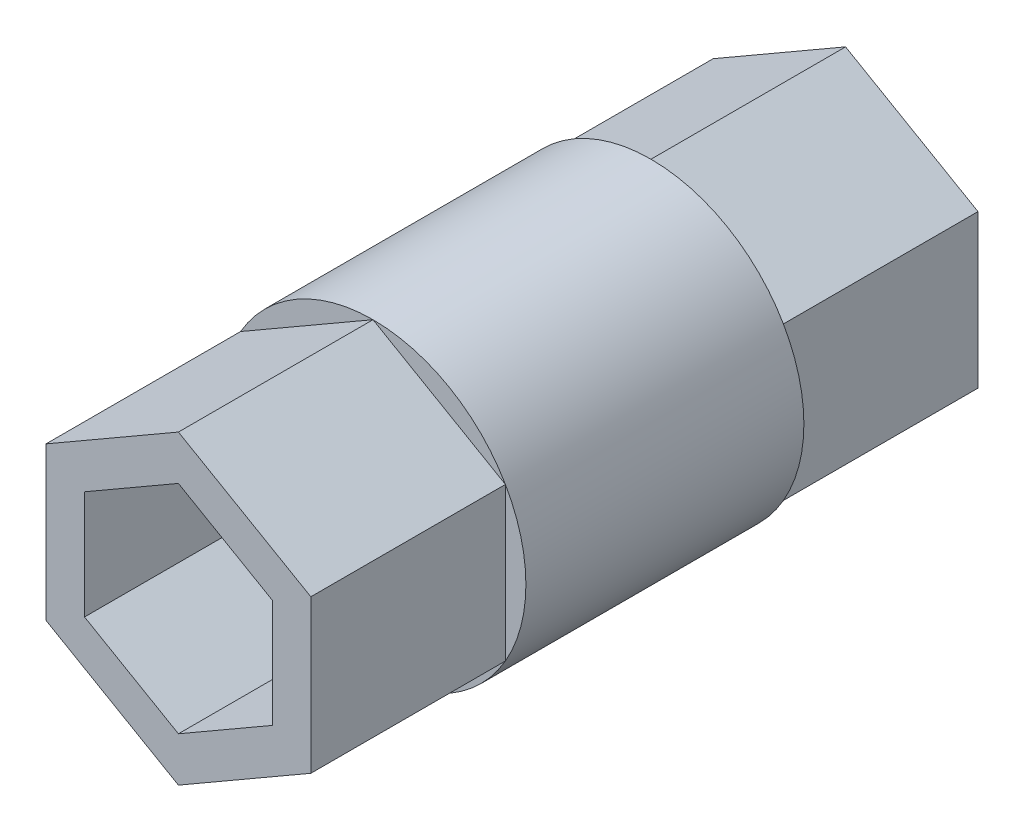
from build123d import *

# Parameters (mm, degrees)
SKETCH1_R           = 11
SKETCH1_R_2         = 6.4
BOSS_EXTRUDE1_DEPTH = 10
BOSS_EXTRUDE2_DEPTH = 24
CUT_EXTRUDE3_DEPTH  = 51.457903246


with BuildPart() as part:
    # Sketch1 → Boss-Extrude1 (new, symmetric)
    with BuildSketch(Plane.XY):
        Circle(SKETCH1_R)
        Circle(SKETCH1_R_2, mode=Mode.SUBTRACT)
    extrude(amount=BOSS_EXTRUDE1_DEPTH, both=True)

    # Sketch1_3 → Boss-Extrude2 (add, symmetric)
    with BuildSketch(Plane.XY):
        Polygon((-9.526279442, -5.5), (0, -11), (9.526279442, -5.5), (9.526279442, 5.5), (0, 11), (-9.526279442, 5.5), align=None)
    extrude(amount=BOSS_EXTRUDE2_DEPTH, both=True)

    # Sketch2 → Cut-Extrude3 (cut, through all)
    with BuildSketch(Plane.XY.offset(24)):
        Polygon((0, -7.8), (6.75499815, -3.9), (6.75499815, 3.9), (0, 7.8), (-6.75499815, 3.9), (-6.75499815, -3.9), align=None)
    extrude(amount=-CUT_EXTRUDE3_DEPTH, mode=Mode.SUBTRACT)


solid = part.part
